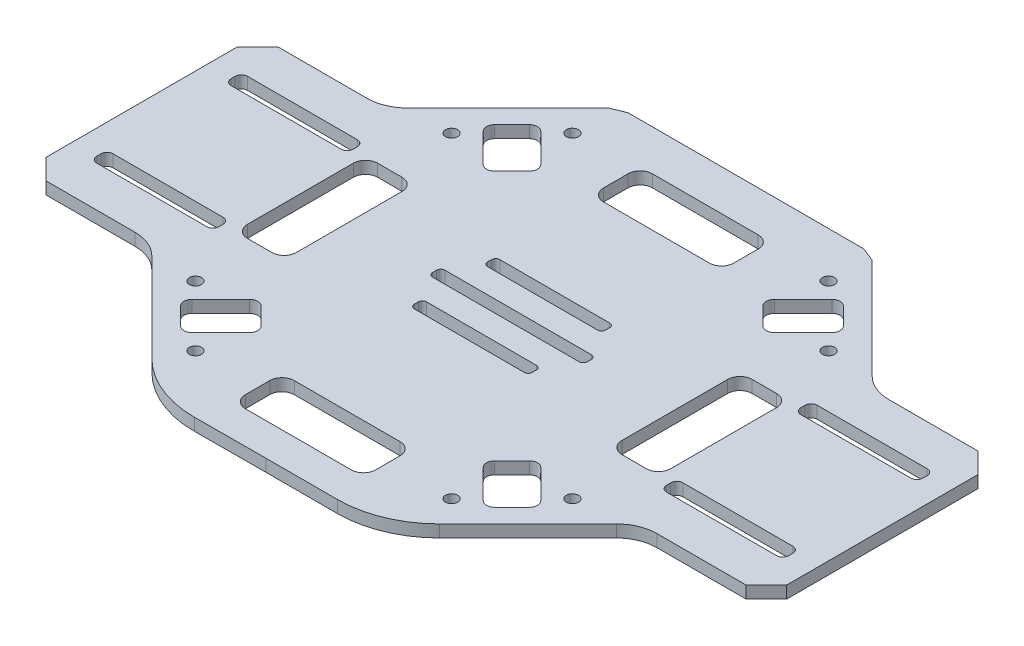
from build123d import *

# Parameters (mm, degrees)
EXTRUDE_1_DEPTH     = 3
SKETCH_2_R          = 1.5
CUT_EXTRUDE_1_DEPTH = 10


with BuildPart() as part:
    # Эскиз1 → Бобышка-Вытянуть1 (new body)
    with BuildSketch(Plane(origin=(0, 0, 0), x_dir=(1, 0, 0), z_dir=(0, 1, 0))):
        with BuildLine():
            Line((134.788230129, -23.5), (134.788230129, 23.5))
            Line((134.788230129, 23.5), (129.788230129, 28.5))
            Line((129.788230129, 28.5), (107.930365753, 28.5))
            ThreePointArc((107.930365753, 28.5), (104.10353143, 29.261204675), (100.859297941, 31.428932188))
            Line((100.859297941, 31.428932188), (76.202443692, 56.085786438))
            Line((76.202443692, 56.085786438), (72.788230129, 57.5))
            Line((72.788230129, 57.5), (71.788230129, 57.5))
            Line((71.788230129, 57.5), (43.788230129, 57.5))
            Line((43.788230129, 57.5), (15.788230129, 57.5))
            Line((15.788230129, 57.5), (14.788230129, 57.5))
            Line((14.788230129, 57.5), (11.374016567, 56.085786438))
            Line((11.374016567, 56.085786438), (-13.282837682, 31.428932188))
            ThreePointArc((-13.282837682, 31.428932188), (-16.527071171, 29.261204675), (-20.353905494, 28.5))
            Line((-20.353905494, 28.5), (-42.211769871, 28.5))
            Line((-42.211769871, 28.5), (-47.211769871, 23.5))
            Line((-47.211769871, 23.5), (-47.211769871, -23.5))
            Line((-47.211769871, -23.5), (-42.211769871, -28.5))
            Line((-42.211769871, -28.5), (-20.353905494, -28.5))
            ThreePointArc((-20.353905494, -28.5), (-16.527071171, -29.261204675), (-13.282837682, -31.428932188))
            Line((-13.282837682, -31.428932188), (8.529786186, -53.241556056))
            ThreePointArc((8.529786186, -53.241556056), (16.682460471, -58.678264424), (26.298538199, -60.563720606))
            Line((26.298538199, -60.563720606), (43.788230129, -60.5))
            Line((43.788230129, -60.5), (61.43289107, -60.5))
            ThreePointArc((61.43289107, -60.5), (70.999976879, -58.596988313), (79.1105606, -53.17766953))
            Line((79.1105606, -53.17766953), (100.859297941, -31.428932188))
            ThreePointArc((100.859297941, -31.428932188), (104.10353143, -29.261204675), (107.930365753, -28.5))
            Line((107.930365753, -28.5), (129.788230129, -28.5))
            Line((129.788230129, -28.5), (134.788230129, -23.5))
        make_face()
        with BuildLine():
            Line((61.788230129, 1.5), (25.788230129, 1.5))
            ThreePointArc((25.788230129, 1.5), (25.081123348, 1.207106781), (24.788230129, 0.5))
            Line((24.788230129, 0.5), (24.788230129, -0.5))
            ThreePointArc((24.788230129, -0.5), (25.081123348, -1.207106781), (25.788230129, -1.5))
            Line((25.788230129, -1.5), (61.788230129, -1.5))
            ThreePointArc((61.788230129, -1.5), (62.495336911, -1.207106781), (62.788230129, -0.5))
            Line((62.788230129, -0.5), (62.788230129, 0.5))
            ThreePointArc((62.788230129, 0.5), (62.495336911, 1.207106781), (61.788230129, 1.5))
        make_face(mode=Mode.SUBTRACT)
        with BuildLine():
            Line((43.788230129, -7.5), (57.288230129, -7.5))
            ThreePointArc((57.288230129, -7.5), (57.995336911, -7.792893219), (58.288230129, -8.5))
            Line((58.288230129, -8.5), (58.288230129, -9.5))
            ThreePointArc((58.288230129, -9.5), (57.995336911, -10.207106781), (57.288230129, -10.5))
            Line((57.288230129, -10.5), (30.288230129, -10.5))
            ThreePointArc((30.288230129, -10.5), (29.581123348, -10.207106781), (29.288230129, -9.5))
            Line((29.288230129, -9.5), (29.288230129, -8.5))
            ThreePointArc((29.288230129, -8.5), (29.581123348, -7.792893219), (30.288230129, -7.5))
            Line((30.288230129, -7.5), (43.788230129, -7.5))
        make_face(mode=Mode.SUBTRACT)
        with BuildLine():
            Line((29.288230129, 9.5), (29.288230129, 8.5))
            ThreePointArc((29.288230129, 8.5), (29.581123348, 7.792893219), (30.288230129, 7.5))
            Line((30.288230129, 7.5), (43.788230129, 7.5))
            Line((43.788230129, 7.5), (57.288230129, 7.5))
            ThreePointArc((57.288230129, 7.5), (57.995336911, 7.792893219), (58.288230129, 8.5))
            Line((58.288230129, 8.5), (58.288230129, 9.5))
            ThreePointArc((58.288230129, 9.5), (57.995336911, 10.207106781), (57.288230129, 10.5))
            Line((57.288230129, 10.5), (30.288230129, 10.5))
            ThreePointArc((30.288230129, 10.5), (29.581123348, 10.207106781), (29.288230129, 9.5))
        make_face(mode=Mode.SUBTRACT)
        with BuildLine():
            Line((128.788230129, -17), (128.788230129, -16))
            ThreePointArc((128.788230129, -16), (128.348890301, -14.939339828), (127.288230129, -14.5))
            Line((127.288230129, -14.5), (100.288230129, -14.5))
            ThreePointArc((100.288230129, -14.5), (99.227569958, -14.939339828), (98.788230129, -16))
            Line((98.788230129, -16), (98.788230129, -17))
            ThreePointArc((98.788230129, -17), (99.227569958, -18.060660172), (100.288230129, -18.5))
            Line((100.288230129, -18.5), (127.288230129, -18.5))
            ThreePointArc((127.288230129, -18.5), (128.348890301, -18.060660172), (128.788230129, -17))
        make_face(mode=Mode.SUBTRACT)
        with BuildLine():
            Line((128.788230129, 17), (128.788230129, 16))
            ThreePointArc((128.788230129, 16), (128.348890301, 14.939339828), (127.288230129, 14.5))
            Line((127.288230129, 14.5), (100.288230129, 14.5))
            ThreePointArc((100.288230129, 14.5), (99.227569958, 14.939339828), (98.788230129, 16))
            Line((98.788230129, 16), (98.788230129, 17))
            ThreePointArc((98.788230129, 17), (99.227569958, 18.060660172), (100.288230129, 18.5))
            Line((100.288230129, 18.5), (127.288230129, 18.5))
            ThreePointArc((127.288230129, 18.5), (128.348890301, 18.060660172), (128.788230129, 17))
        make_face(mode=Mode.SUBTRACT)
        with BuildLine():
            Line((-41.211769871, -17), (-41.211769871, -16))
            ThreePointArc((-41.211769871, -16), (-40.772430042, -14.939339828), (-39.711769871, -14.5))
            Line((-39.711769871, -14.5), (-12.711769871, -14.5))
            ThreePointArc((-12.711769871, -14.5), (-11.651109699, -14.939339828), (-11.211769871, -16))
            Line((-11.211769871, -16), (-11.211769871, -17))
            ThreePointArc((-11.211769871, -17), (-11.651109699, -18.060660172), (-12.711769871, -18.5))
            Line((-12.711769871, -18.5), (-39.711769871, -18.5))
            ThreePointArc((-39.711769871, -18.5), (-40.772430042, -18.060660172), (-41.211769871, -17))
        make_face(mode=Mode.SUBTRACT)
        with BuildLine():
            Line((-11.211769871, 16), (-11.211769871, 17))
            ThreePointArc((-11.211769871, 17), (-11.651109699, 18.060660172), (-12.711769871, 18.5))
            Line((-12.711769871, 18.5), (-39.711769871, 18.5))
            ThreePointArc((-39.711769871, 18.5), (-40.772430042, 18.060660172), (-41.211769871, 17))
            Line((-41.211769871, 17), (-41.211769871, 16))
            ThreePointArc((-41.211769871, 16), (-40.772430042, 14.939339828), (-39.711769871, 14.5))
            Line((-39.711769871, 14.5), (-12.711769871, 14.5))
            ThreePointArc((-12.711769871, 14.5), (-11.651109699, 14.939339828), (-11.211769871, 16))
        make_face(mode=Mode.SUBTRACT)
        with BuildLine():
            Line((83.788230129, 0), (83.788230129, 13))
            ThreePointArc((83.788230129, 13), (84.666909786, 15.121320344), (86.788230129, 16))
            Line((86.788230129, 16), (92.788230129, 16))
            ThreePointArc((92.788230129, 16), (94.909550473, 15.121320344), (95.788230129, 13))
            Line((95.788230129, 13), (95.788230129, 0))
            Line((95.788230129, 0), (95.788230129, -13))
            ThreePointArc((95.788230129, -13), (94.909550473, -15.121320344), (92.788230129, -16))
            Line((92.788230129, -16), (86.788230129, -16))
            ThreePointArc((86.788230129, -16), (84.666909786, -15.121320344), (83.788230129, -13))
            Line((83.788230129, -13), (83.788230129, 0))
        make_face(mode=Mode.SUBTRACT)
        with BuildLine():
            Line((-8.211769871, 0), (-8.211769871, 13))
            ThreePointArc((-8.211769871, 13), (-7.333090214, 15.121320344), (-5.211769871, 16))
            Line((-5.211769871, 16), (0.788230129, 16))
            ThreePointArc((0.788230129, 16), (2.909550473, 15.121320344), (3.788230129, 13))
            Line((3.788230129, 13), (3.788230129, 0))
            Line((3.788230129, 0), (3.788230129, -13))
            ThreePointArc((3.788230129, -13), (2.909550473, -15.121320344), (0.788230129, -16))
            Line((0.788230129, -16), (-5.211769871, -16))
            ThreePointArc((-5.211769871, -16), (-7.333090214, -15.121320344), (-8.211769871, -13))
            Line((-8.211769871, -13), (-8.211769871, 0))
        make_face(mode=Mode.SUBTRACT)
        with BuildLine():
            Line((86.624677476, 35.764057717), (79.553609664, 28.692989905))
            ThreePointArc((79.553609664, 28.692989905), (78.139396102, 28.107203467), (76.725182539, 28.692989905))
            Line((76.725182539, 28.692989905), (72.482541852, 32.935630592))
            ThreePointArc((72.482541852, 32.935630592), (71.896755414, 34.349844155), (72.482541852, 35.764057717))
            Line((72.482541852, 35.764057717), (79.553609664, 42.835125529))
            ThreePointArc((79.553609664, 42.835125529), (80.967823226, 43.420911966), (82.382036789, 42.835125529))
            Line((82.382036789, 42.835125529), (84.503357132, 40.713805185))
            Line((84.503357132, 40.713805185), (86.624677476, 38.592484842))
            ThreePointArc((86.624677476, 38.592484842), (87.210463913, 37.178271279), (86.624677476, 35.764057717))
        make_face(mode=Mode.SUBTRACT)
        with BuildLine():
            Line((43.788230129, -52.5), (56.788230129, -52.5))
            ThreePointArc((56.788230129, -52.5), (58.909550473, -51.621320344), (59.788230129, -49.5))
            Line((59.788230129, -49.5), (59.788230129, -43.5))
            ThreePointArc((59.788230129, -43.5), (58.909550473, -41.378679656), (56.788230129, -40.5))
            Line((56.788230129, -40.5), (43.788230129, -40.5))
            Line((43.788230129, -40.5), (30.788230129, -40.5))
            ThreePointArc((30.788230129, -40.5), (28.666909786, -41.378679656), (27.788230129, -43.5))
            Line((27.788230129, -43.5), (27.788230129, -49.5))
            ThreePointArc((27.788230129, -49.5), (28.666909786, -51.621320344), (30.788230129, -52.5))
            Line((30.788230129, -52.5), (43.788230129, -52.5))
        make_face(mode=Mode.SUBTRACT)
        with BuildLine():
            Line((3.073103127, 40.713805185), (5.19442347, 42.835125529))
            ThreePointArc((5.19442347, 42.835125529), (6.608637033, 43.420911966), (8.022850595, 42.835125529))
            Line((8.022850595, 42.835125529), (15.093918407, 35.764057717))
            ThreePointArc((15.093918407, 35.764057717), (15.679704844, 34.349844155), (15.093918407, 32.935630592))
            Line((15.093918407, 32.935630592), (10.85127772, 28.692989905))
            ThreePointArc((10.85127772, 28.692989905), (9.437064157, 28.107203467), (8.022850595, 28.692989905))
            Line((8.022850595, 28.692989905), (0.951782783, 35.764057717))
            ThreePointArc((0.951782783, 35.764057717), (0.365996345, 37.178271279), (0.951782783, 38.592484842))
            Line((0.951782783, 38.592484842), (3.073103127, 40.713805185))
        make_face(mode=Mode.SUBTRACT)
        with BuildLine():
            Line((43.788230129, 47.5), (56.788230129, 47.5))
            ThreePointArc((56.788230129, 47.5), (58.909550473, 46.621320344), (59.788230129, 44.5))
            Line((59.788230129, 44.5), (59.788230129, 38.5))
            ThreePointArc((59.788230129, 38.5), (58.909550473, 36.378679656), (56.788230129, 35.5))
            Line((56.788230129, 35.5), (30.788230129, 35.5))
            ThreePointArc((30.788230129, 35.5), (28.666909786, 36.378679656), (27.788230129, 38.5))
            Line((27.788230129, 38.5), (27.788230129, 44.5))
            ThreePointArc((27.788230129, 44.5), (28.666909786, 46.621320344), (30.788230129, 47.5))
            Line((30.788230129, 47.5), (43.788230129, 47.5))
        make_face(mode=Mode.SUBTRACT)
        with BuildLine():
            Line((3.073103127, -40.713805185), (5.19442347, -42.835125529))
            ThreePointArc((5.19442347, -42.835125529), (6.608637033, -43.420911966), (8.022850595, -42.835125529))
            Line((8.022850595, -42.835125529), (15.093918407, -35.764057717))
            ThreePointArc((15.093918407, -35.764057717), (15.679704844, -34.349844155), (15.093918407, -32.935630592))
            Line((15.093918407, -32.935630592), (10.85127772, -28.692989905))
            ThreePointArc((10.85127772, -28.692989905), (9.437064157, -28.107203467), (8.022850595, -28.692989905))
            Line((8.022850595, -28.692989905), (0.951782783, -35.764057717))
            ThreePointArc((0.951782783, -35.764057717), (0.365996345, -37.178271279), (0.951782783, -38.592484842))
            Line((0.951782783, -38.592484842), (3.073103127, -40.713805185))
        make_face(mode=Mode.SUBTRACT)
        with BuildLine():
            Line((72.482541852, -32.935630592), (76.725182539, -28.692989905))
            ThreePointArc((76.725182539, -28.692989905), (78.139396102, -28.107203467), (79.553609664, -28.692989905))
            Line((79.553609664, -28.692989905), (86.624677476, -35.764057717))
            ThreePointArc((86.624677476, -35.764057717), (87.210463913, -37.178271279), (86.624677476, -38.592484842))
            Line((86.624677476, -38.592484842), (84.503357132, -40.713805185))
            Line((84.503357132, -40.713805185), (82.382036789, -42.835125529))
            ThreePointArc((82.382036789, -42.835125529), (80.967823226, -43.420911966), (79.553609664, -42.835125529))
            Line((79.553609664, -42.835125529), (72.482541852, -35.764057717))
            ThreePointArc((72.482541852, -35.764057717), (71.896755414, -34.349844155), (72.482541852, -32.935630592))
        make_face(mode=Mode.SUBTRACT)
    extrude(amount=EXTRUDE_1_DEPTH)

    # Эскиз2 → Вырез-Вытянуть1 (cut)
    with BuildSketch(Plane(origin=(0, 3, 0), x_dir=(1, 0, 0), z_dir=(0, 1, 0))):
        with Locations((12.321978367, 46.315494168)):
            Circle(SKETCH_2_R)
        with Locations((-2.527264038, 31.466251763)):
            Circle(SKETCH_2_R)
        with Locations((90.103724297, 31.466251763)):
            Circle(SKETCH_2_R)
        with Locations((75.254481892, 46.315494168)):
            Circle(SKETCH_2_R)
        with Locations((90.103724297, -31.466251763)):
            Circle(SKETCH_2_R)
        with Locations((75.254481892, -46.315494168)):
            Circle(SKETCH_2_R)
        with Locations((-2.527264038, -31.466251763)):
            Circle(SKETCH_2_R)
        with Locations((12.321978367, -46.315494168)):
            Circle(SKETCH_2_R)
    extrude(amount=-CUT_EXTRUDE_1_DEPTH, mode=Mode.SUBTRACT)


solid = part.part
